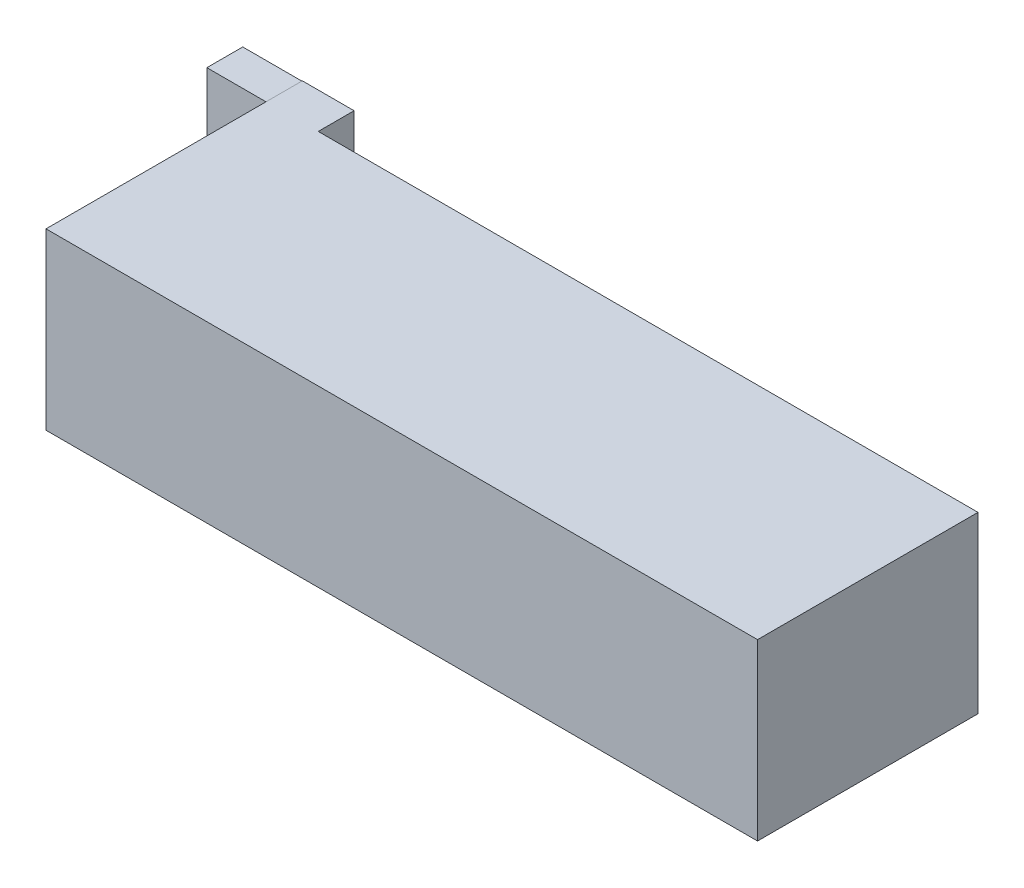
from build123d import *

# Parameters (mm, degrees)
SKETCH2_W           = 135.26
SKETCH2_H           = 41.91
BOSS_EXTRUDE1_DEPTH = 33.16
SKETCH3_W           = 9.84
SKETCH3_H           = 6.82
BOSS_EXTRUDE2_DEPTH = 33.16
SKETCH7_W           = 11.33
SKETCH7_H           = 33.072325858
BOSS_EXTRUDE3_DEPTH = 6.82


with BuildPart() as part:
    # Sketch2 → Boss-Extrude1 (new body)
    with BuildSketch(Plane(origin=(0, 0, 0), x_dir=(1, 0, 0), z_dir=(0, 1, 0))):
        with Locations((67.63, 20.955)):
            Rectangle(SKETCH2_W, SKETCH2_H)
    extrude(amount=BOSS_EXTRUDE1_DEPTH)

    # Sketch3 → Boss-Extrude2 (add)
    with BuildSketch(Plane(origin=(0, 0, 0), x_dir=(1, 0, 0), z_dir=(0, 1, 0))):
        with Locations((4.92, 45.32)):
            Rectangle(SKETCH3_W, SKETCH3_H)
    extrude(amount=BOSS_EXTRUDE2_DEPTH)

    # Sketch7 → Boss-Extrude3 (add)
    with BuildSketch(Plane(origin=(0, 0, -48.73), x_dir=(-1, 0, 0), z_dir=(0, 0, -1))):
        with Locations((5.665, 16.536162929)):
            Rectangle(SKETCH7_W, SKETCH7_H)
    extrude(amount=-BOSS_EXTRUDE3_DEPTH)


solid = part.part
